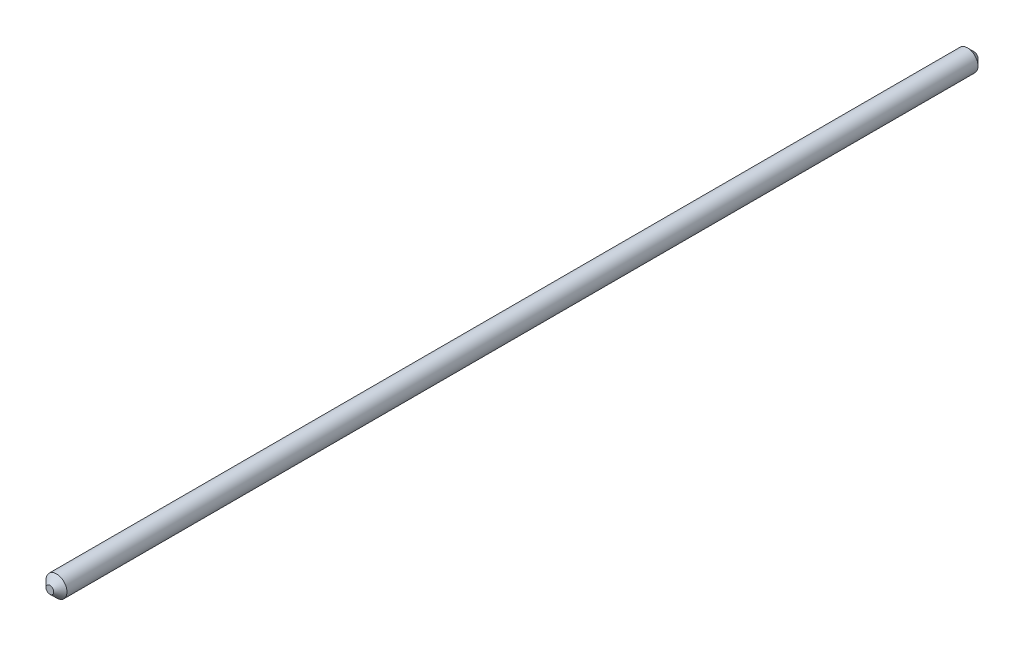
from build123d import *

# Parameters (mm, degrees)
SKETCH1_R           = 3.175
BOSS_EXTRUDE1_DEPTH = 280
CHAMFER1_SIZE       = 2


with BuildPart() as part:
    # Sketch1 → Boss-Extrude1 (new body)
    with BuildSketch(Plane.XY):
        Circle(SKETCH1_R)
    extrude(amount=BOSS_EXTRUDE1_DEPTH)

    # Chamfer1
    chamfer1_edges = [part.edges().sort_by_distance(p)[0] for p in [
        (-3.175, 0, 0),
        (-3.175, 0, 280),
    ]]
    chamfer(chamfer1_edges, length=CHAMFER1_SIZE)


solid = part.part
